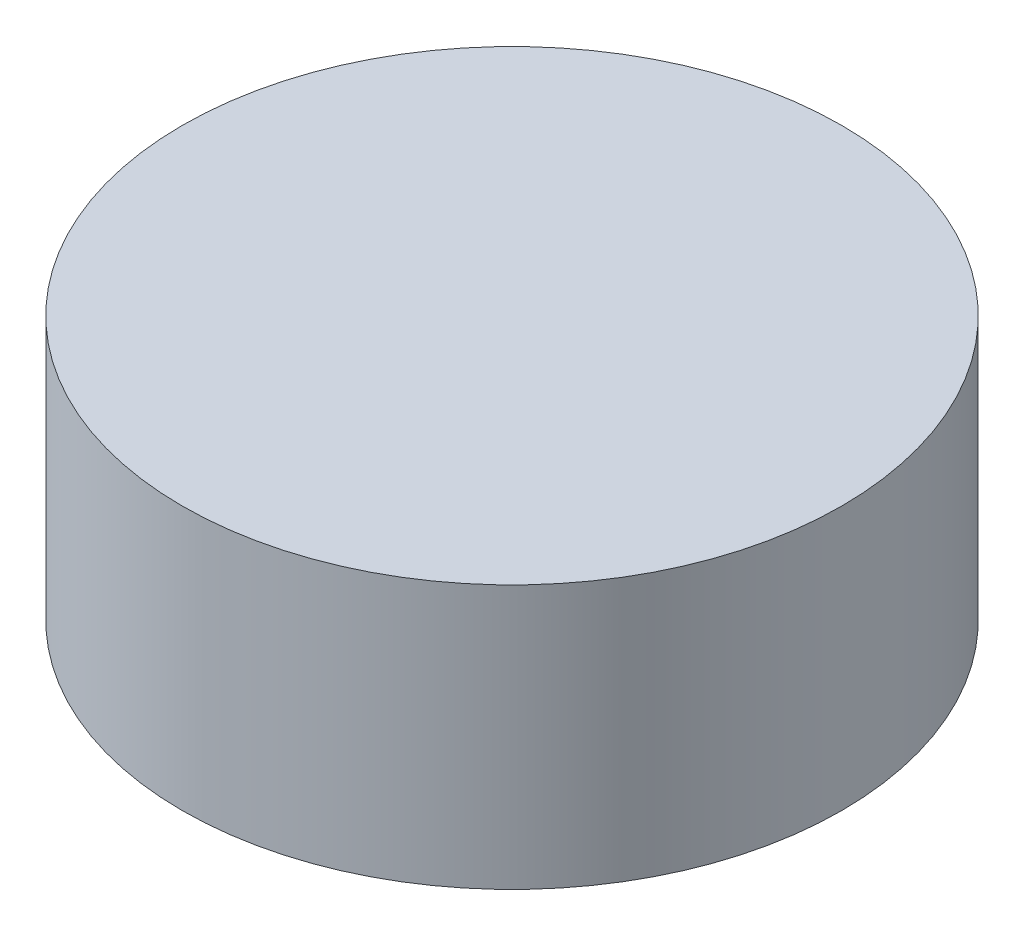
from build123d import *

# Parameters (mm, degrees)
CROQUIS1_R              = 1.25
SALIENTE_EXTRUIR1_DEPTH = 1


with BuildPart() as part:
    # Croquis1 → Saliente-Extruir1 (new body)
    with BuildSketch(Plane(origin=(0, 0, 0), x_dir=(1, 0, 0), z_dir=(0, 1, 0))):
        Circle(CROQUIS1_R)
    extrude(amount=SALIENTE_EXTRUIR1_DEPTH)


solid = part.part
